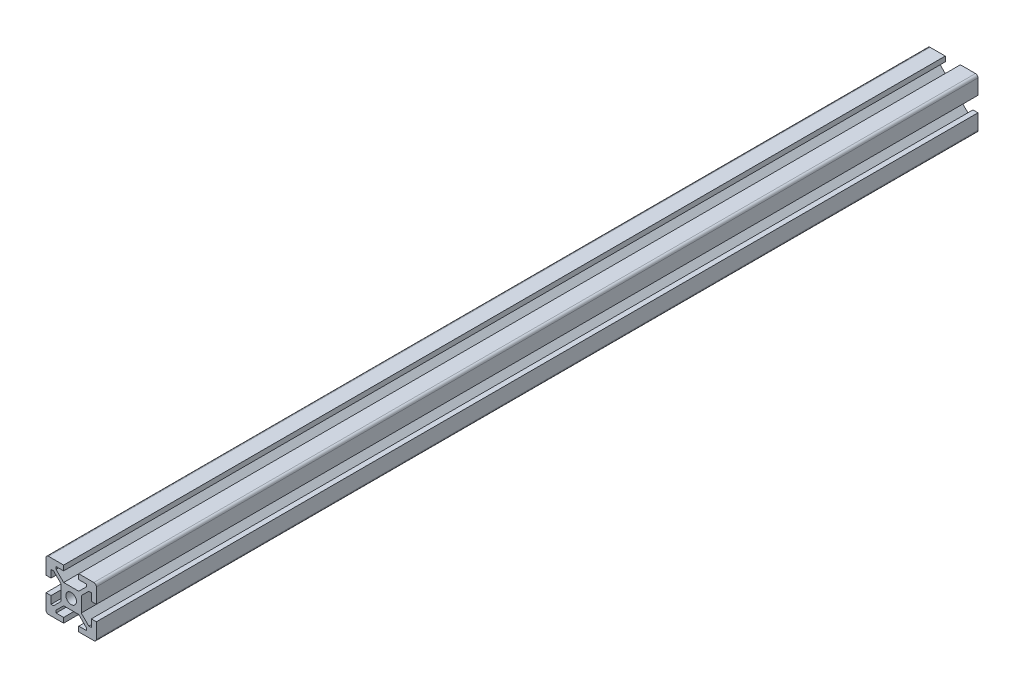
from build123d import *

# Parameters (mm, degrees)
SCHIZZO1_R                   = 2.1
ESTRUSIONE_ESTRUSIONE1_DEPTH = 350
RACCORDO1_R                  = 1


with BuildPart() as part:
    # Schizzo1 → Estrusione-Estrusione1 (new body)
    with BuildSketch(Plane.XY):
        Polygon((10, 3), (10, 10), (3, 10), (3, 8), (6, 8), (6, 7), (3, 4), (-3, 4), (-6, 7), (-6, 8), (-3, 8), (-3, 10), (-10, 10), (-10, 3), (-8, 3), (-8, 6), (-7, 6), (-4, 3), (-4, -3), (-7, -6), (-8, -6), (-8, -3), (-10, -3), (-10, -10), (-3, -10), (-3, -8), (-6, -8), (-6, -7), (-3, -4), (3, -4), (6, -7), (6, -8), (3, -8), (3, -10), (10, -10), (10, -3), (8, -3), (8, -6), (7, -6), (4, -3), (4, 3), (7, 6), (8, 6), (8, 3), align=None)
        Circle(SCHIZZO1_R, mode=Mode.SUBTRACT)
    extrude(amount=ESTRUSIONE_ESTRUSIONE1_DEPTH)

    # Raccordo1
    raccordo1_edges = [part.edges().sort_by_distance(p)[0] for p in [
        (-10, 10, 175),
        (10, 10, 175),
        (10, -10, 175),
        (-10, -10, 175),
    ]]
    fillet(raccordo1_edges, radius=RACCORDO1_R)


solid = part.part
